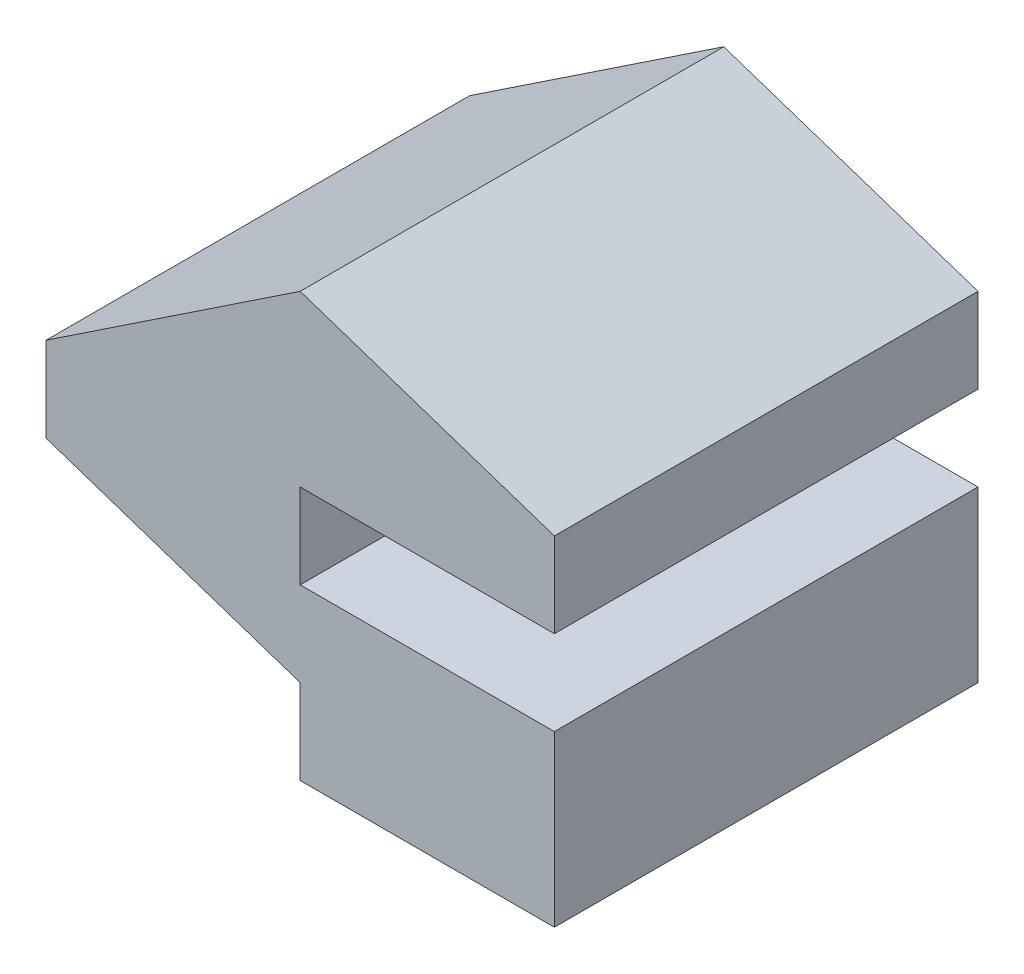
from build123d import *

# Parameters (mm, degrees)
BOSS_EXTRUDE16_DEPTH = 5


with BuildPart() as part:
    # Sketch26 → Boss-Extrude16 (new body)
    with BuildSketch(Plane.XY):
        Polygon((0, 0), (0, 1), (-3, 2), (-3, 3), (0, 5), (3, 4), (3, 3), (0, 3), (0, 2), (3, 2), (3, 0), align=None)
    extrude(amount=BOSS_EXTRUDE16_DEPTH)


solid = part.part
